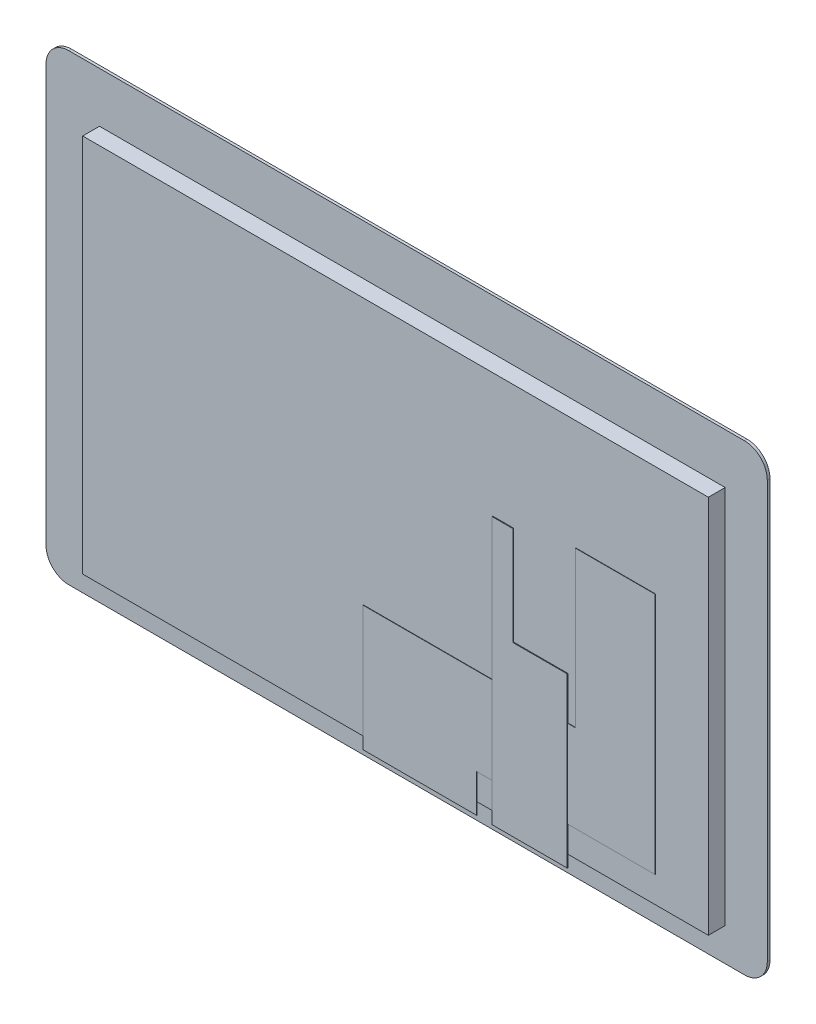
from build123d import *

# Parameters (mm, degrees)
BOSS_EXTRUDE1_DEPTH      = 0.7
SKETCH2_W                = 153.84
SKETCH2_H                = 85.63
CUT_EXTRUDE1_DEPTH       = 0.8
SKETCH3_W                = 153.84
SKETCH3_H                = 85.63
BOSS_EXTRUDE4_DEPTH      = 0.75
BOSS_EXTRUDE4_DEPTH_BACK = 0.05
SKETCH4_W                = 164.9
SKETCH4_H                = 100
BOSS_EXTRUDE5_DEPTH      = 4.43
BOSS_EXTRUDE6_DEPTH      = 0.1
BOSS_EXTRUDE7_DEPTH      = 0.2


with BuildPart() as part:
    # Sketch1 → Boss-Extrude1 (new body)
    with BuildSketch(Plane.XY):
        with BuildLine():
            Line((-89.04, 60.96), (89.04, 60.96))
            ThreePointArc((89.04, 60.96), (93.282640687, 59.202640687), (95.04, 54.96))
            Line((95.04, 54.96), (95.04, -54.96))
            ThreePointArc((95.04, -54.96), (93.282640687, -59.202640687), (89.04, -60.96))
            Line((89.04, -60.96), (-89.04, -60.96))
            ThreePointArc((-89.04, -60.96), (-93.282640687, -59.202640687), (-95.04, -54.96))
            Line((-95.04, -54.96), (-95.04, 54.96))
            ThreePointArc((-95.04, 54.96), (-93.282640687, 59.202640687), (-89.04, 60.96))
        make_face()
    extrude(amount=BOSS_EXTRUDE1_DEPTH)

    # Sketch2 → Cut-Extrude1 (cut)
    with BuildSketch(Plane.XY):
        with Locations((0, -0.005)):
            Rectangle(SKETCH2_W, SKETCH2_H)
    extrude(amount=CUT_EXTRUDE1_DEPTH, mode=Mode.SUBTRACT)

    # Sketch3 → Boss-Extrude4 (add, two sides)
    with BuildSketch(Plane.XY) as boss_extrude4_sk:
        with Locations((0, -0.005)):
            Rectangle(SKETCH3_W, SKETCH3_H)
    extrude(amount=BOSS_EXTRUDE4_DEPTH)
    extrude(boss_extrude4_sk.sketch, amount=-BOSS_EXTRUDE4_DEPTH_BACK)

    # Sketch4 → Boss-Extrude5 (add)
    with BuildSketch(Plane.XY.offset(0.7)):
        with Locations((1.49, -2.26)):
            Rectangle(SKETCH4_W, SKETCH4_H)
    extrude(amount=BOSS_EXTRUDE5_DEPTH)

    # Sketch5 → Boss-Extrude6 (add)
    with BuildSketch(Plane.XY.offset(5.13)):
        Polygon((48.995697603, 18.69), (69.995697603, 18.69), (69.995697603, -45.31), (22.995697603, -45.31), (22.995697603, -55.31), (-7.004302397, -55.31), (-7.004302397, -22.31), (48.995697603, -22.31), align=None)
    extrude(amount=BOSS_EXTRUDE6_DEPTH)

    # Sketch6 → Boss-Extrude7 (add)
    with BuildSketch(Plane.XY.offset(5.13)):
        Polygon((32.59, 15.01), (27.09, 15.01), (27.09, -55.31), (46.94, -55.31), (46.94, -10.99), (32.59, -10.99), align=None)
    extrude(amount=BOSS_EXTRUDE7_DEPTH)


solid = part.part
